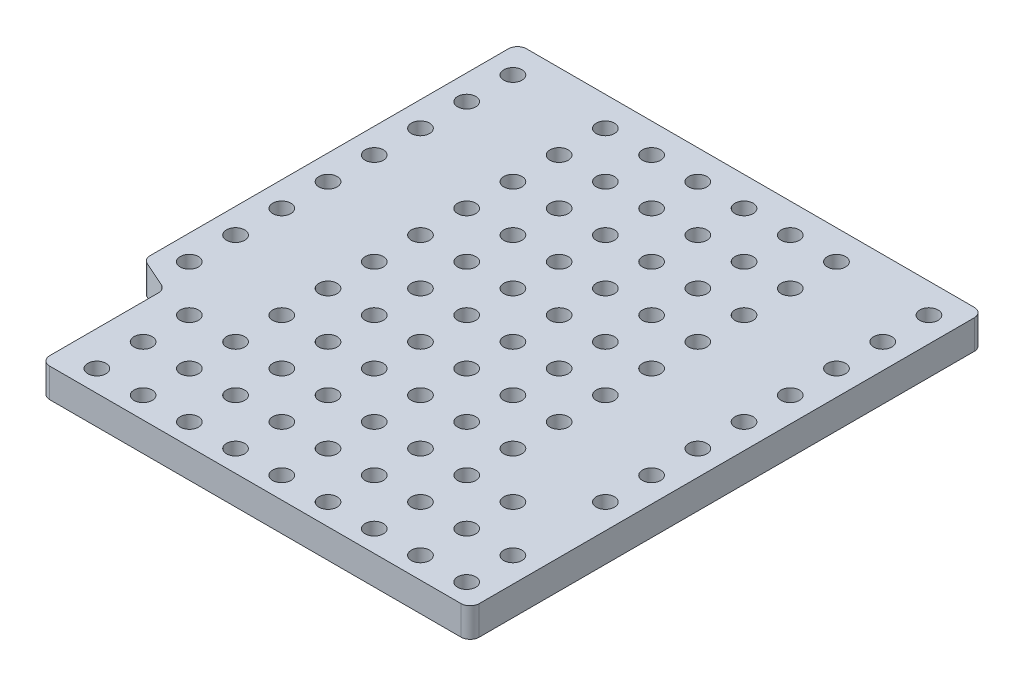
from build123d import *

# Parameters (mm, degrees)
SKETCH2_R           = 0.5
BOSS_EXTRUDE1_DEPTH = 1.6
FILLET1_R           = 0.5
SKETCH3_R           = 0.5
CUT_EXTRUDE1_DEPTH  = 32.010320863


with BuildPart() as part:
    # Sketch2 → Boss-Extrude1 (new body)
    with BuildSketch(Plane(origin=(0, 0, 0), x_dir=(1, 0, 0), z_dir=(0, 1, 0))):
        Polygon((-12.8, 7.690457371), (-12.8, 28.2), (12.8, 28.2), (12.8, 0), (-10.8, 0), (-10.8, 6.8), align=None)
        with Locations((-11.43, 26.58)):
            Circle(SKETCH2_R, mode=Mode.SUBTRACT)
        with Locations((11.43, 26.58)):
            Circle(SKETCH2_R, mode=Mode.SUBTRACT)
        with Locations((-11.43, 24.04)):
            Circle(SKETCH2_R, mode=Mode.SUBTRACT)
        with Locations((11.43, 24.04)):
            Circle(SKETCH2_R, mode=Mode.SUBTRACT)
        with Locations((-11.43, 21.5)):
            Circle(SKETCH2_R, mode=Mode.SUBTRACT)
        with Locations((11.43, 21.5)):
            Circle(SKETCH2_R, mode=Mode.SUBTRACT)
        with Locations((-11.43, 18.96)):
            Circle(SKETCH2_R, mode=Mode.SUBTRACT)
        with Locations((11.43, 18.96)):
            Circle(SKETCH2_R, mode=Mode.SUBTRACT)
        with Locations((-11.43, 16.42)):
            Circle(SKETCH2_R, mode=Mode.SUBTRACT)
        with Locations((11.43, 16.42)):
            Circle(SKETCH2_R, mode=Mode.SUBTRACT)
        with Locations((-11.43, 13.88)):
            Circle(SKETCH2_R, mode=Mode.SUBTRACT)
        with Locations((11.43, 13.88)):
            Circle(SKETCH2_R, mode=Mode.SUBTRACT)
        with Locations((-11.43, 11.34)):
            Circle(SKETCH2_R, mode=Mode.SUBTRACT)
        with Locations((11.43, 11.34)):
            Circle(SKETCH2_R, mode=Mode.SUBTRACT)
        with Locations((-11.43, 8.8)):
            Circle(SKETCH2_R, mode=Mode.SUBTRACT)
        with Locations((11.43, 8.8)):
            Circle(SKETCH2_R, mode=Mode.SUBTRACT)
    extrude(amount=BOSS_EXTRUDE1_DEPTH)

    # Fillet1
    fillet1_edges = [part.edges().sort_by_distance(p)[0] for p in [
        (-10.8, 0.8, 0),
        (-10.8, 0.8, -6.8),
        (-12.8, 0.8, -7.690457371),
        (-12.8, 0.8, -28.2),
        (12.8, 0.8, -28.2),
        (12.8, 0.8, 0),
    ]]
    fillet(fillet1_edges, radius=FILLET1_R)

    # Sketch3 → Cut-Extrude1 (cut, through all)
    with BuildSketch(Plane.XZ):
        with Locations((-6.35, -26.58)):
            Circle(SKETCH3_R)
        with Locations((-3.81, -26.58)):
            Circle(SKETCH3_R)
        with Locations((-1.27, -26.58)):
            Circle(SKETCH3_R)
        with Locations((1.27, -26.58)):
            Circle(SKETCH3_R)
        with Locations((3.81, -26.58)):
            Circle(SKETCH3_R)
        with Locations((6.35, -26.58)):
            Circle(SKETCH3_R)
        with Locations((-3.81, -24.04)):
            Circle(SKETCH3_R)
        with Locations((-1.27, -24.04)):
            Circle(SKETCH3_R)
        with Locations((1.27, -24.04)):
            Circle(SKETCH3_R)
        with Locations((3.81, -24.04)):
            Circle(SKETCH3_R)
        with Locations((6.35, -24.04)):
            Circle(SKETCH3_R)
        with Locations((-3.81, -21.5)):
            Circle(SKETCH3_R)
        with Locations((-1.27, -21.5)):
            Circle(SKETCH3_R)
        with Locations((1.27, -21.5)):
            Circle(SKETCH3_R)
        with Locations((3.81, -21.5)):
            Circle(SKETCH3_R)
        with Locations((6.35, -21.5)):
            Circle(SKETCH3_R)
        with Locations((-3.81, -18.96)):
            Circle(SKETCH3_R)
        with Locations((-1.27, -18.96)):
            Circle(SKETCH3_R)
        with Locations((1.27, -18.96)):
            Circle(SKETCH3_R)
        with Locations((3.81, -18.96)):
            Circle(SKETCH3_R)
        with Locations((6.35, -18.96)):
            Circle(SKETCH3_R)
        with Locations((-3.81, -16.42)):
            Circle(SKETCH3_R)
        with Locations((-1.27, -16.42)):
            Circle(SKETCH3_R)
        with Locations((1.27, -16.42)):
            Circle(SKETCH3_R)
        with Locations((3.81, -16.42)):
            Circle(SKETCH3_R)
        with Locations((6.35, -16.42)):
            Circle(SKETCH3_R)
        with Locations((-3.81, -13.88)):
            Circle(SKETCH3_R)
        with Locations((-1.27, -13.88)):
            Circle(SKETCH3_R)
        with Locations((1.27, -13.88)):
            Circle(SKETCH3_R)
        with Locations((3.81, -13.88)):
            Circle(SKETCH3_R)
        with Locations((6.35, -13.88)):
            Circle(SKETCH3_R)
        with Locations((-3.81, -11.34)):
            Circle(SKETCH3_R)
        with Locations((-1.27, -11.34)):
            Circle(SKETCH3_R)
        with Locations((1.27, -11.34)):
            Circle(SKETCH3_R)
        with Locations((3.81, -11.34)):
            Circle(SKETCH3_R)
        with Locations((6.35, -11.34)):
            Circle(SKETCH3_R)
        with Locations((-3.81, -8.8)):
            Circle(SKETCH3_R)
        with Locations((-1.27, -8.8)):
            Circle(SKETCH3_R)
        with Locations((1.27, -8.8)):
            Circle(SKETCH3_R)
        with Locations((3.81, -8.8)):
            Circle(SKETCH3_R)
        with Locations((6.35, -8.8)):
            Circle(SKETCH3_R)
        with Locations((-6.35, -24.04)):
            Circle(SKETCH3_R)
        with Locations((-6.35, -21.5)):
            Circle(SKETCH3_R)
        with Locations((-6.35, -18.96)):
            Circle(SKETCH3_R)
        with Locations((-6.35, -16.42)):
            Circle(SKETCH3_R)
        with Locations((-6.35, -13.88)):
            Circle(SKETCH3_R)
        with Locations((-6.35, -11.34)):
            Circle(SKETCH3_R)
        with Locations((-6.35, -8.8)):
            Circle(SKETCH3_R)
        with Locations((-8.89, -6.26)):
            Circle(SKETCH3_R)
        with Locations((-6.35, -6.26)):
            Circle(SKETCH3_R)
        with Locations((-3.81, -6.26)):
            Circle(SKETCH3_R)
        with Locations((-1.27, -6.26)):
            Circle(SKETCH3_R)
        with Locations((1.27, -6.26)):
            Circle(SKETCH3_R)
        with Locations((3.81, -6.26)):
            Circle(SKETCH3_R)
        with Locations((6.35, -6.26)):
            Circle(SKETCH3_R)
        with Locations((8.89, -6.26)):
            Circle(SKETCH3_R)
        with Locations((-6.35, -3.72)):
            Circle(SKETCH3_R)
        with Locations((-3.81, -3.72)):
            Circle(SKETCH3_R)
        with Locations((-1.27, -3.72)):
            Circle(SKETCH3_R)
        with Locations((1.27, -3.72)):
            Circle(SKETCH3_R)
        with Locations((3.81, -3.72)):
            Circle(SKETCH3_R)
        with Locations((6.35, -3.72)):
            Circle(SKETCH3_R)
        with Locations((8.89, -3.72)):
            Circle(SKETCH3_R)
        with Locations((-6.35, -1.18)):
            Circle(SKETCH3_R)
        with Locations((-3.81, -1.18)):
            Circle(SKETCH3_R)
        with Locations((-1.27, -1.18)):
            Circle(SKETCH3_R)
        with Locations((1.27, -1.18)):
            Circle(SKETCH3_R)
        with Locations((3.81, -1.18)):
            Circle(SKETCH3_R)
        with Locations((6.35, -1.18)):
            Circle(SKETCH3_R)
        with Locations((8.89, -1.18)):
            Circle(SKETCH3_R)
        with Locations((-8.89, -3.72)):
            Circle(SKETCH3_R)
        with Locations((-8.89, -1.18)):
            Circle(SKETCH3_R)
        with Locations((11.43, -3.72)):
            Circle(SKETCH3_R)
        with Locations((11.43, -1.18)):
            Circle(SKETCH3_R)
    extrude(amount=-CUT_EXTRUDE1_DEPTH, mode=Mode.SUBTRACT)


solid = part.part
